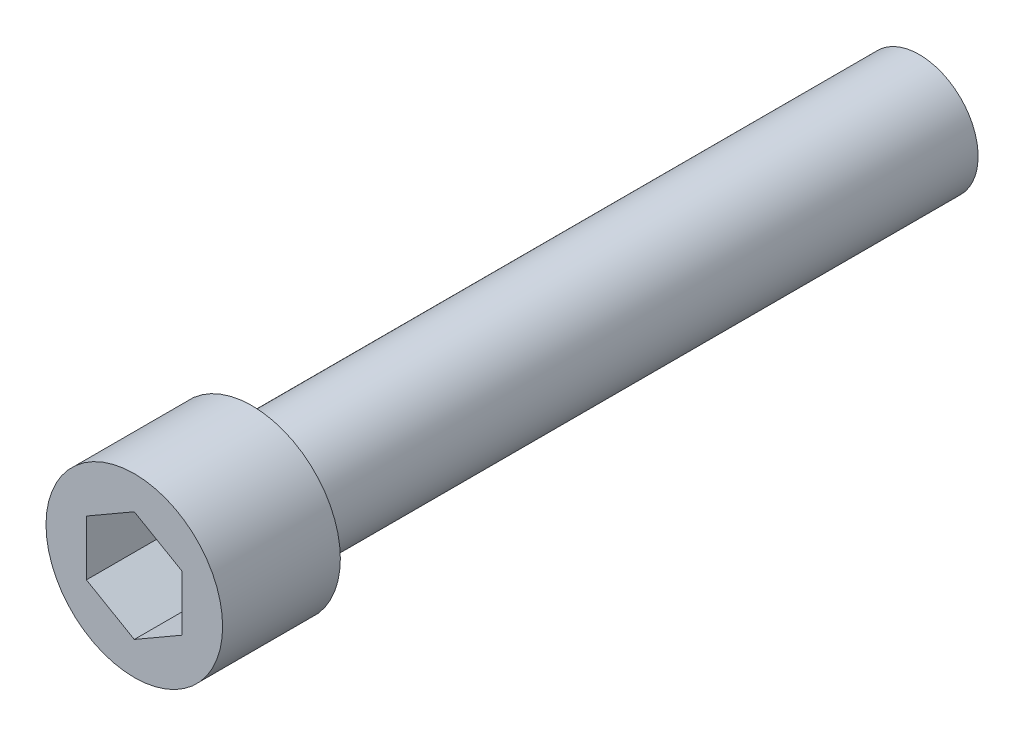
from build123d import *

# Parameters (mm, degrees)
SKETCH1_R           = 4.5
BOSS_EXTRUDE1_DEPTH = 4
SKETCH2_R           = 4.5
BOSS_EXTRUDE2_DEPTH = 2
SKETCH3_R           = 3
BOSS_EXTRUDE3_DEPTH = 34


with BuildPart() as part:
    # Sketch1 → Boss-Extrude1 (new body)
    with BuildSketch(Plane.XY):
        Circle(SKETCH1_R)
        Polygon((0, 2.817703613), (-2.440202909, 1.408851806), (-2.440202909, -1.408851806), (0, -2.817703613), (2.440202909, -1.408851806), (2.440202909, 1.408851806), align=None, mode=Mode.SUBTRACT)
    extrude(amount=BOSS_EXTRUDE1_DEPTH)

    # Sketch2 → Boss-Extrude2 (add)
    with BuildSketch(Plane(origin=(0, 0, 0), x_dir=(-1, 0, 0), z_dir=(0, 0, -1))):
        Circle(SKETCH2_R)
    extrude(amount=BOSS_EXTRUDE2_DEPTH)

    # Sketch3 → Boss-Extrude3 (add)
    with BuildSketch(Plane(origin=(0, 0, -2), x_dir=(-1, 0, 0), z_dir=(0, 0, -1))):
        Circle(SKETCH3_R)
    extrude(amount=BOSS_EXTRUDE3_DEPTH)


solid = part.part
